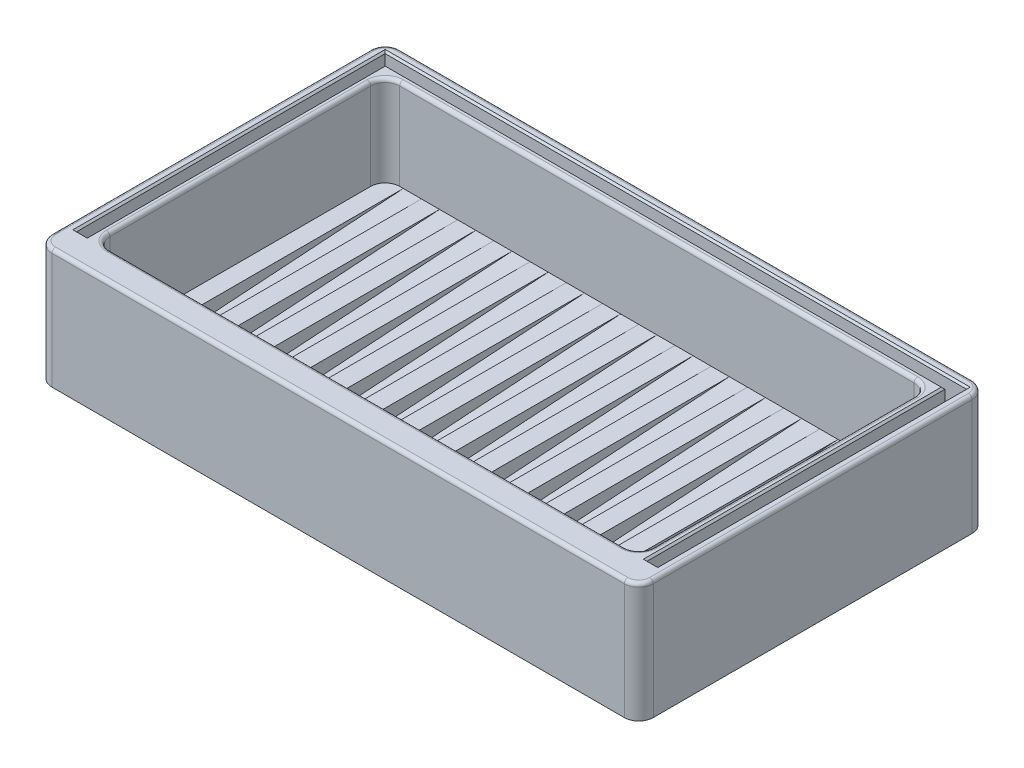
from build123d import *

# Parameters (mm, degrees)
SKETCH1_W           = 166
SKETCH1_H           = 96
BOSS_EXTRUDE1_DEPTH = 33
SKETCH2_W           = 150
SKETCH2_H           = 80
CUT_EXTRUDE1_DEPTH  = 30
BOSS_EXTRUDE2_DEPTH = 5
SKETCH5_W           = 75
SKETCH5_H           = 5
BOSS_EXTRUDE3_DEPTH = 5
LPATTERN1_COUNT     = 15
LPATTERN1_PITCH     = 10
CUT_EXTRUDE5_DEPTH  = 10
FILLET1_R           = 4
FILLET2_R           = 4
FILLET3_R           = 2
FILLET5_R           = 1
CHAMFER1_SIZE       = 0.5


with BuildPart() as part:
    # Sketch1 → Boss-Extrude1 (new body)
    with BuildSketch(Plane(origin=(0, 0, 0), x_dir=(1, 0, 0), z_dir=(0, 1, 0))):
        with Locations((18.075570249, -18.706715624)):
            Rectangle(SKETCH1_W, SKETCH1_H)
    extrude(amount=BOSS_EXTRUDE1_DEPTH)

    # Sketch2 → Cut-Extrude1 (cut)
    with BuildSketch(Plane(origin=(0, 33, 0), x_dir=(1, 0, 0), z_dir=(0, 1, 0))):
        with Locations((18.075570249, -18.706715624)):
            Rectangle(SKETCH2_W, SKETCH2_H)
    extrude(amount=-CUT_EXTRUDE1_DEPTH, mode=Mode.SUBTRACT)

    # Sketch4 → Boss-Extrude2 (add)
    with BuildSketch(Plane.ZY.offset(-93.075570249)):
        Polygon((53.706715624, 3), (-21.293284376, 8), (-21.293284376, 3), align=None)
    boss_extrude2 = extrude(amount=BOSS_EXTRUDE2_DEPTH)

    # Sketch5 → Boss-Extrude3 (add)
    with BuildSketch(Plane.ZY.offset(-88.075570249)):
        with Locations((16.206715624, 5.5)):
            Rectangle(SKETCH5_W, SKETCH5_H)
    boss_extrude3 = extrude(amount=BOSS_EXTRUDE3_DEPTH)

    # LPattern1: Boss-Extrude2, Boss-Extrude3 ×15
    with Locations(*[(-i * LPATTERN1_PITCH, 0, 0) for i in range(1, LPATTERN1_COUNT)]):
        add(boss_extrude2)
        add(boss_extrude3)

    # Sketch9 → Cut-Extrude5 (cut)
    with BuildSketch(Plane(origin=(0, 33, 0), x_dir=(1, 0, 0), z_dir=(0, 1, 0))):
        Polygon((-62.174429751, 26.543284376), (98.325570249, 26.543284376), (98.325570249, -58.706715624), (95.325570249, -58.706715624), (95.325570249, 23.543284376), (-59.174429751, 23.543284376), (-59.174429751, -58.706715624), (-62.174429751, -58.706715624), align=None)
    extrude(amount=-CUT_EXTRUDE5_DEPTH, mode=Mode.SUBTRACT)

    # Fillet1
    fillet1_edges = [part.edges().sort_by_distance(p)[0] for p in [
        (-64.924429751, 16.5, -29.293284376),
        (101.075570249, 16.5, -29.293284376),
        (101.075570249, 16.5, 66.706715624),
        (-64.924429751, 16.5, 66.706715624),
    ]]
    fillet(fillet1_edges, radius=FILLET1_R)

    # Fillet2
    fillet2_edges = [part.edges().sort_by_distance(p)[0] for p in [
        (-56.924429751, 18, 58.706715624),
        (93.075570249, 18, 58.706715624),
        (93.075570249, 20.5, -21.293284376),
        (-56.924429751, 20.5, -21.293284376),
    ]]
    fillet(fillet2_edges, radius=FILLET2_R)

    # Fillet3
    fillet3_edges = [part.edges().sort_by_distance(p)[0] for p in [
        (75.575570249, 8, 53.706715624),
        (65.575570249, 8, 53.706715624),
        (55.575570249, 8, 53.706715624),
        (45.575570249, 8, 53.706715624),
        (35.575570249, 8, 53.706715624),
        (25.575570249, 8, 53.706715624),
        (15.575570249, 8, 53.706715624),
        (5.575570249, 8, 53.706715624),
        (-4.424429751, 8, 53.706715624),
        (-14.424429751, 8, 53.706715624),
        (-24.424429751, 8, 53.706715624),
        (-34.424429751, 8, 53.706715624),
        (-44.424429751, 8, 53.706715624),
        (-54.424429751, 8, 53.706715624),
        (85.575570249, 8, 53.706715624),
    ]]
    fillet(fillet3_edges, radius=FILLET3_R)

    # Fillet5
    fillet5_edges = [part.edges().sort_by_distance(p)[0] for p in [
        (-64.924429751, 33, 18.706715624),
        (18.075570249, 33, -29.293284376),
        (18.075570249, 33, 66.706715624),
        (101.075570249, 33, 18.706715624),
        (-63.752856875, 33, 65.535142749),
        (99.903997374, 33, 65.535142749),
        (99.903997374, 33, -28.1217115),
        (-63.752856875, 33, -28.1217115),
        (93.075570249, 33, 18.706715624),
        (18.075570249, 33, 58.706715624),
        (18.075570249, 33, -21.293284376),
        (-56.924429751, 33, 18.706715624),
        (91.903997374, 33, 57.535142749),
        (91.903997374, 33, -20.1217115),
        (-55.752856875, 33, -20.1217115),
        (-55.752856875, 33, 57.535142749),
    ]]
    fillet(fillet5_edges, radius=FILLET5_R)

    # Chamfer1
    chamfer1_edges = [part.edges().sort_by_distance(p)[0] for p in [
        (-62.174429751, 33, 16.081715624),
        (-60.674429751, 33, 58.706715624),
        (-59.174429751, 33, 17.581715624),
        (18.075570249, 33, -23.543284376),
        (95.325570249, 33, 17.581715624),
        (96.825570249, 33, 58.706715624),
        (98.325570249, 33, 16.081715624),
        (18.075570249, 33, -26.543284376),
    ]]
    chamfer(chamfer1_edges, length=CHAMFER1_SIZE)


solid = part.part
